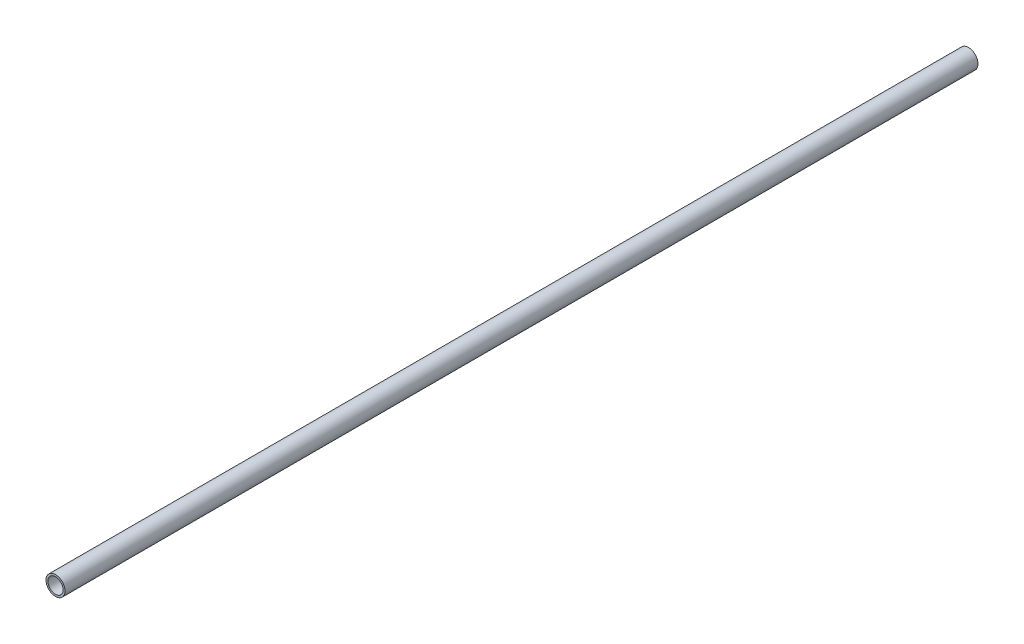
from build123d import *

# Parameters (mm, degrees)
SKETCH1_R           = 12.7
SKETCH1_R_2         = 10.16
BOSS_EXTRUDE1_DEPTH = 1219.2


with BuildPart() as part:
    # Sketch1 → Boss-Extrude1 (new body)
    with BuildSketch(Plane.XY):
        Circle(SKETCH1_R)
        Circle(SKETCH1_R_2, mode=Mode.SUBTRACT)
    extrude(amount=BOSS_EXTRUDE1_DEPTH)


solid = part.part
